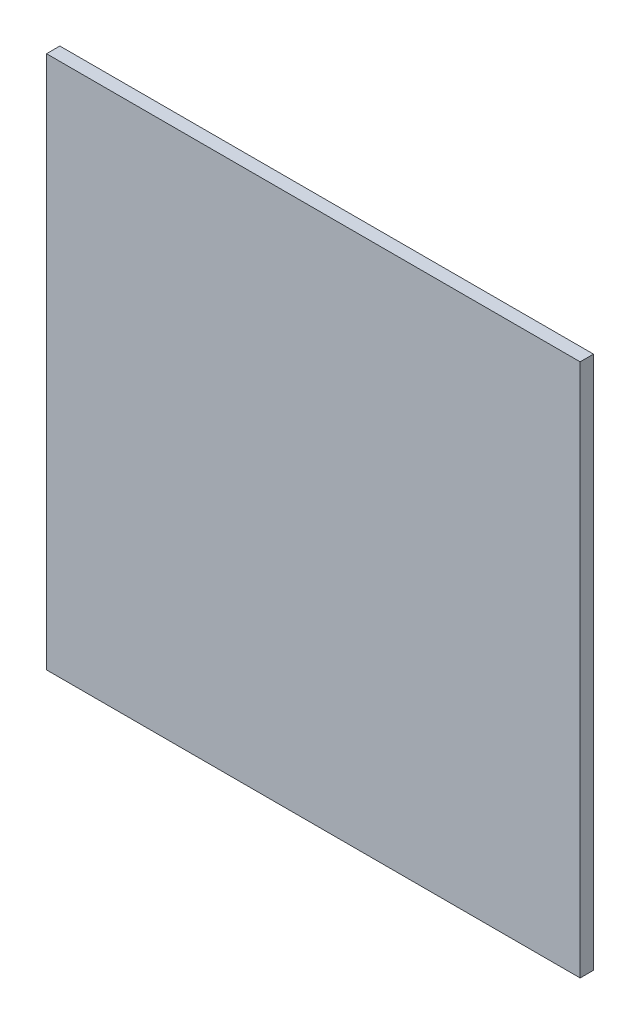
from build123d import *

# Parameters (mm, degrees)
ESQUISSE1_W        = 400
ESQUISSE1_H        = 400
BOSS_EXTRU_1_DEPTH = 10


with BuildPart() as part:
    # Esquisse1 → Boss.-Extru.1 (new body)
    with BuildSketch(Plane.XY):
        Rectangle(ESQUISSE1_W, ESQUISSE1_H)
    extrude(amount=BOSS_EXTRU_1_DEPTH)


solid = part.part
